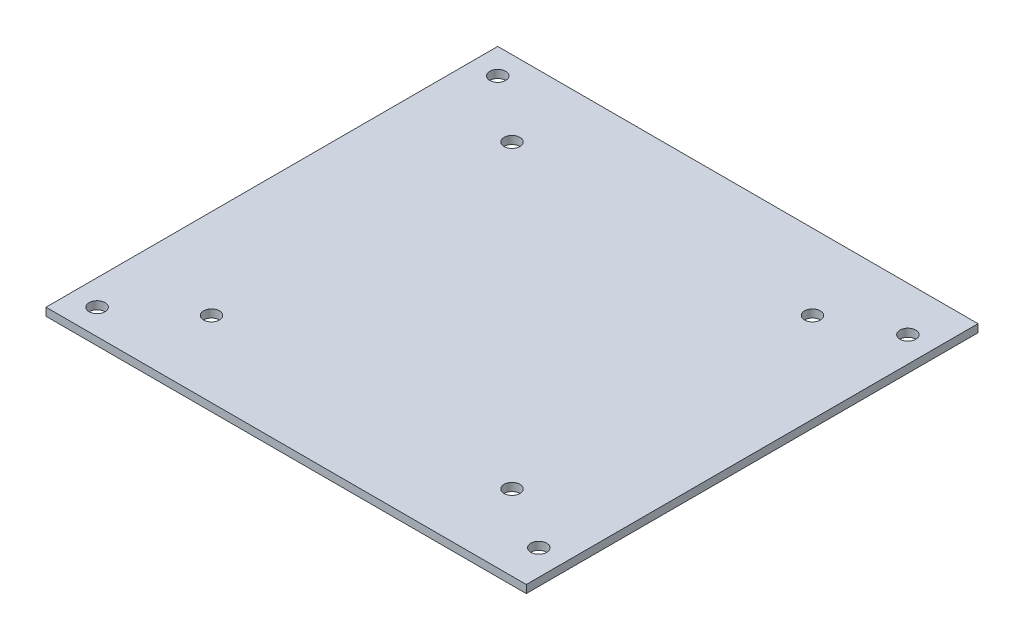
from build123d import *

# Parameters (mm, degrees)
SKETCH2_W           = 95.9
SKETCH2_H           = 90.2
SKETCH2_R           = 1.5875
BOSS_EXTRUDE1_DEPTH = 1.58


with BuildPart() as part:
    # Sketch2 → Boss-Extrude1 (new body)
    with BuildSketch(Plane(origin=(0, 0, 0), x_dir=(1, 0, 0), z_dir=(0, 1, 0))):
        Rectangle(SKETCH2_W, SKETCH2_H)
        with Locations((30, 30)):
            Circle(SKETCH2_R, mode=Mode.SUBTRACT)
        with Locations((30, -30)):
            Circle(SKETCH2_R, mode=Mode.SUBTRACT)
        with Locations((-30, -30)):
            Circle(SKETCH2_R, mode=Mode.SUBTRACT)
        with Locations((-30, 30)):
            Circle(SKETCH2_R, mode=Mode.SUBTRACT)
        with Locations((-42.85, 40)):
            Circle(SKETCH2_R, mode=Mode.SUBTRACT)
        with Locations((-42.85, -40)):
            Circle(SKETCH2_R, mode=Mode.SUBTRACT)
        with Locations((42.85, 36.2)):
            Circle(SKETCH2_R, mode=Mode.SUBTRACT)
        with Locations((42.85, -37.5)):
            Circle(SKETCH2_R, mode=Mode.SUBTRACT)
    extrude(amount=BOSS_EXTRUDE1_DEPTH)


solid = part.part
